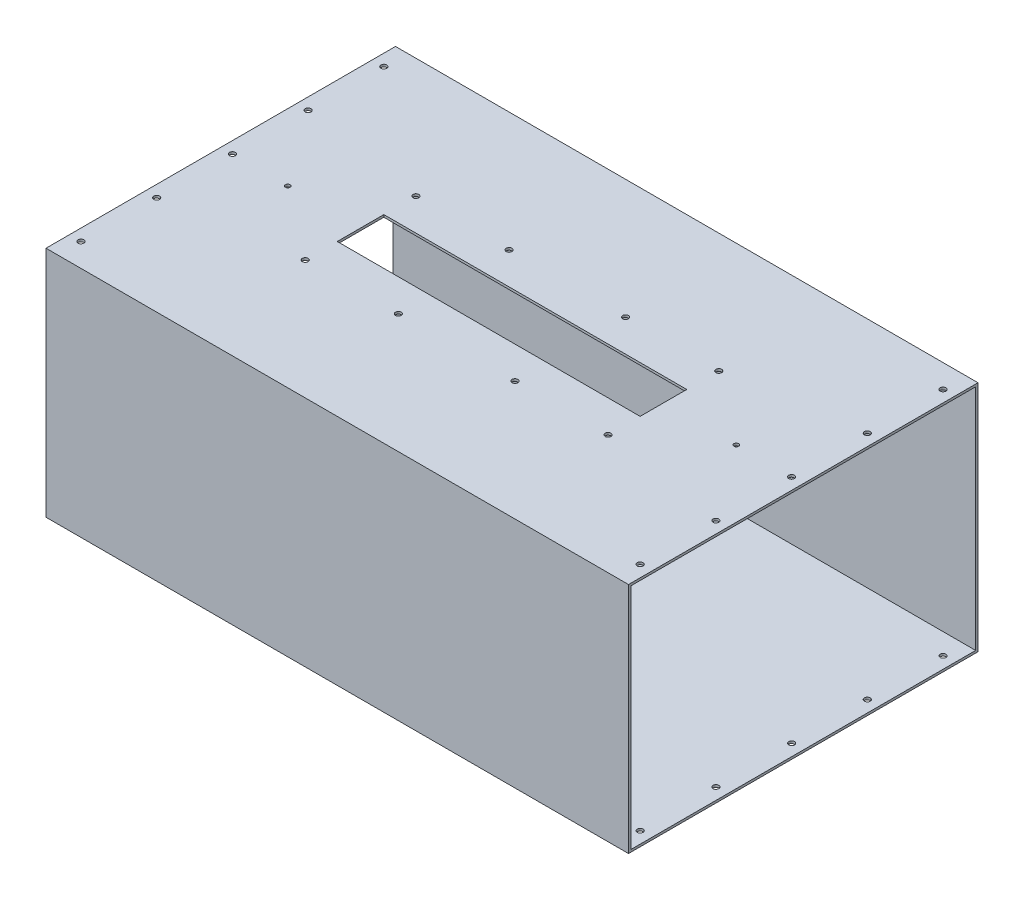
from build123d import *

# Parameters (mm, degrees)
ESBO_O1_W                = 300
ESBO_O1_H                = 200
RESSALTO_EXTRUS_O1_DEPTH = 500
ESBO_O2_W                = 296
ESBO_O2_H                = 196
CORTE_EXTRUS_O1_DEPTH    = 501
ESBO_O3_R                = 2
ESBO_O3_R_2              = 2.5
ESBO_O3_W                = 260
ESBO_O3_H                = 40
CORTE_EXTRUS_O2_DEPTH    = 10
ESBO_O5_R                = 2.5
CORTE_EXTRUS_O3_DEPTH    = 201


with BuildPart() as part:
    # Esboço1 → Ressalto-extrusão1 (new body)
    with BuildSketch(Plane(origin=(0, 0, 0), x_dir=(0, 0, -1), z_dir=(1, 0, 0))):
        Rectangle(ESBO_O1_W, ESBO_O1_H)
    extrude(amount=RESSALTO_EXTRUS_O1_DEPTH)

    # Esboço2 → Corte-extrusão1 (cut, through all)
    with BuildSketch(Plane(origin=(500, 0, 0), x_dir=(0, 0, -1), z_dir=(1, 0, 0))):
        Rectangle(ESBO_O2_W, ESBO_O2_H)
    extrude(amount=-CORTE_EXTRUS_O1_DEPTH, mode=Mode.SUBTRACT)

    # Esboço3 → Corte-extrusão2 (cut)
    with BuildSketch(Plane(origin=(0, 100, 0), x_dir=(1, 0, 0), z_dir=(0, 1, 0))):
        with Locations((57.5, 0)):
            Circle(ESBO_O3_R)
        with Locations((442.5, 0)):
            Circle(ESBO_O3_R)
        with Locations((120, 47.5)):
            Circle(ESBO_O3_R_2)
        with Locations((200, 47.5)):
            Circle(ESBO_O3_R_2)
        with Locations((300, 47.5)):
            Circle(ESBO_O3_R_2)
        with Locations((380, 47.5)):
            Circle(ESBO_O3_R_2)
        with Locations((380, -47.5)):
            Circle(ESBO_O3_R_2)
        with Locations((300, -47.5)):
            Circle(ESBO_O3_R_2)
        with Locations((200, -47.5)):
            Circle(ESBO_O3_R_2)
        with Locations((120, -47.5)):
            Circle(ESBO_O3_R_2)
        with Locations((250, 0)):
            Rectangle(ESBO_O3_W, ESBO_O3_H)
    extrude(amount=-CORTE_EXTRUS_O2_DEPTH, mode=Mode.SUBTRACT)

    # Esboço5 → Corte-extrusão3 (cut, through all)
    with BuildSketch(Plane(origin=(0, 100, 0), x_dir=(1, 0, 0), z_dir=(0, 1, 0))):
        with Locations((490, 130)):
            Circle(ESBO_O5_R)
        with Locations((490, 65)):
            Circle(ESBO_O5_R)
        with Locations((490, 0)):
            Circle(ESBO_O5_R)
        with Locations((490, -65)):
            Circle(ESBO_O5_R)
        with Locations((490, -130)):
            Circle(ESBO_O5_R)
        with Locations((10, -130)):
            Circle(ESBO_O5_R)
        with Locations((10, -65)):
            Circle(ESBO_O5_R)
        with Locations((10, 0)):
            Circle(ESBO_O5_R)
        with Locations((10, 65)):
            Circle(ESBO_O5_R)
        with Locations((10, 130)):
            Circle(ESBO_O5_R)
    extrude(amount=-CORTE_EXTRUS_O3_DEPTH, mode=Mode.SUBTRACT)


solid = part.part
